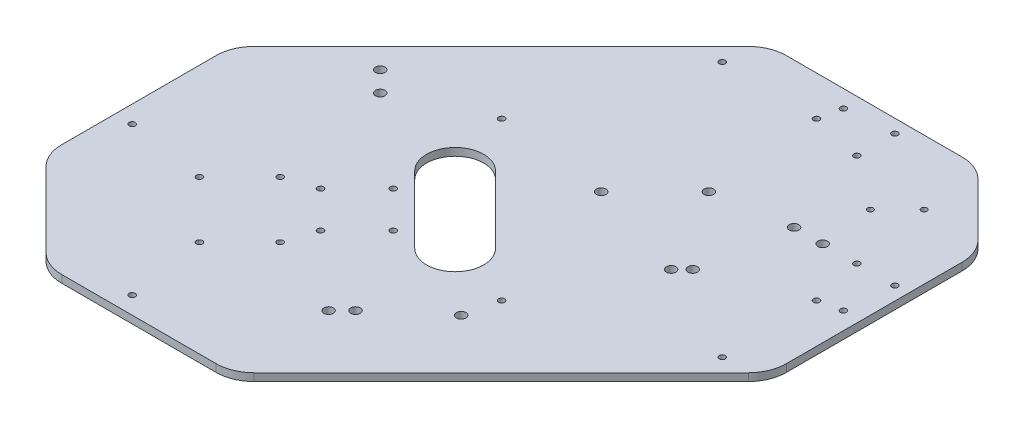
from build123d import *

# Parameters (mm, degrees)
SKETCH2_R           = 1.6
SKETCH2_R_2         = 1.5
SKETCH2_R_3         = 2.5
BOSS_EXTRUDE1_DEPTH = 4


with BuildPart() as part:
    # Sketch2 → Boss-Extrude1 (new body)
    with BuildSketch(Plane(origin=(0, 0, 0), x_dir=(1, 0, 0), z_dir=(0, 1, 0))):
        with BuildLine():
            Line((-139.142135624, 9.350288425), (-9.350288425, 139.142135624))
            ThreePointArc((-9.350288425, 139.142135624), (-2.861821449, 143.47759065), (4.791847198, 145))
            Line((4.791847198, 145), (97.21825407, 145))
            ThreePointArc((97.21825407, 145), (104.871922717, 143.47759065), (111.360389693, 139.142135624))
            Line((111.360389693, 139.142135624), (139.142135624, 111.360389693))
            ThreePointArc((139.142135624, 111.360389693), (143.47759065, 104.871922717), (145, 97.218254069))
            Line((145, 97.218254069), (145, 4.791847198))
            ThreePointArc((145, 4.791847198), (143.47759065, -2.861821449), (139.142135624, -9.350288426))
            Line((139.142135624, -9.350288426), (9.350288425, -139.142135624))
            ThreePointArc((9.350288425, -139.142135624), (2.861821449, -143.47759065), (-4.791847198, -145))
            Line((-4.791847198, -145), (-85.90454557, -145))
            ThreePointArc((-85.90454557, -145), (-93.558214218, -143.47759065), (-100.046681194, -139.142135624))
            Line((-100.046681194, -139.142135624), (-139.142135624, -100.046681194))
            ThreePointArc((-139.142135624, -100.046681194), (-143.47759065, -93.558214218), (-145, -85.90454557))
            Line((-145, -85.90454557), (-145, -4.791847198))
            ThreePointArc((-145, -4.791847198), (-143.47759065, 2.861821449), (-139.142135624, 9.350288425))
        make_face()
        with Locations((-94.138564286, -64.440079476)):
            Circle(SKETCH2_R, mode=Mode.SUBTRACT)
        with Locations((-64.440079476, -94.138564286)):
            Circle(SKETCH2_R, mode=Mode.SUBTRACT)
        with Locations((-41.272384311, 41.459109088)):
            Circle(SKETCH2_R, mode=Mode.SUBTRACT)
        with Locations((41.459109088, -41.272384311)):
            Circle(SKETCH2_R, mode=Mode.SUBTRACT)
        with Locations((124.190602487, 41.459109088)):
            Circle(SKETCH2_R, mode=Mode.SUBTRACT)
        with Locations((41.459109088, 124.190602487)):
            Circle(SKETCH2_R, mode=Mode.SUBTRACT)
        with Locations((-135.857864376, -58.076118446)):
            Circle(SKETCH2_R, mode=Mode.SUBTRACT)
        with Locations((-58.076118446, -135.857864376)):
            Circle(SKETCH2_R, mode=Mode.SUBTRACT)
        with Locations((-43.226876041, -72.925360851)):
            Circle(SKETCH2_R, mode=Mode.SUBTRACT)
        with Locations((-72.925360851, -43.226876041)):
            Circle(SKETCH2_R, mode=Mode.SUBTRACT)
        with Locations((111.109127035, 111.109127035)):
            Circle(SKETCH2_R_2, mode=Mode.SUBTRACT)
        with Locations((96.966991411, 96.966991411)):
            Circle(SKETCH2_R_2, mode=Mode.SUBTRACT)
        with Locations((-57.015458274, -37.923575182)):
            Circle(SKETCH2_R, mode=Mode.SUBTRACT)
        with Locations((-37.923575182, -57.015458274)):
            Circle(SKETCH2_R, mode=Mode.SUBTRACT)
        with Locations((-18.83169209, -37.923575182)):
            Circle(SKETCH2_R, mode=Mode.SUBTRACT)
        with Locations((-37.923575182, -18.83169209)):
            Circle(SKETCH2_R, mode=Mode.SUBTRACT)
        with Locations((138, 68.86291501)):
            Circle(SKETCH2_R, mode=Mode.SUBTRACT)
        with Locations((118, 68.86291501)):
            Circle(SKETCH2_R, mode=Mode.SUBTRACT)
        with Locations((68.86291501, 138)):
            Circle(SKETCH2_R, mode=Mode.SUBTRACT)
        with Locations((68.86291501, 118)):
            Circle(SKETCH2_R, mode=Mode.SUBTRACT)
        with Locations((-9.099025767, 125.251262658)):
            Circle(SKETCH2_R, mode=Mode.SUBTRACT)
        with Locations((125.251262658, -9.099025767)):
            Circle(SKETCH2_R, mode=Mode.SUBTRACT)
        with Locations((77.521554928, 23.074332777)):
            Circle(SKETCH2_R_3, mode=Mode.SUBTRACT)
        with Locations((71.864700679, 17.417478528)):
            Circle(SKETCH2_R_3, mode=Mode.SUBTRACT)
        with Locations((43.933982822, 135.857864376)):
            Circle(SKETCH2_R, mode=Mode.SUBTRACT)
        with Locations((135.857864376, 43.933982822)):
            Circle(SKETCH2_R, mode=Mode.SUBTRACT)
        with Locations((18.124585309, 34.388041276)):
            Circle(SKETCH2_R_3, mode=Mode.SUBTRACT)
        with Locations((46.408856556, 62.672312523)):
            Circle(SKETCH2_R_3, mode=Mode.SUBTRACT)
        with Locations((-95.435846132, 31.843374482)):
            Circle(SKETCH2_R_3, mode=Mode.SUBTRACT)
        with Locations((-84.829244414, 21.236772764)):
            Circle(SKETCH2_R_3, mode=Mode.SUBTRACT)
        with Locations((85, 68.86291501)):
            Circle(SKETCH2_R_3, mode=Mode.SUBTRACT)
        with Locations((100, 68.86291501)):
            Circle(SKETCH2_R_3, mode=Mode.SUBTRACT)
        with Locations((37.570021791, -58.59650045)):
            Circle(SKETCH2_R_3, mode=Mode.SUBTRACT)
        with Locations((7.684812205, -84.23906935)):
            Circle(SKETCH2_R_3, mode=Mode.SUBTRACT)
        with Locations((0.613744393, -91.310137162)):
            Circle(SKETCH2_R_3, mode=Mode.SUBTRACT)
        with BuildLine():
            Line((-19.18524548, 16.170093579), (16.170093579, -19.18524548))
            ThreePointArc((16.170093579, -19.18524548), (16.170093579, -40.398448916), (-5.043109857, -40.398448916))
            Line((-5.043109857, -40.398448916), (-40.398448916, -5.043109857))
            ThreePointArc((-40.398448916, -5.043109857), (-40.398448916, 16.170093579), (-19.18524548, 16.170093579))
        make_face(mode=Mode.SUBTRACT)
    extrude(amount=BOSS_EXTRUDE1_DEPTH)


solid = part.part
